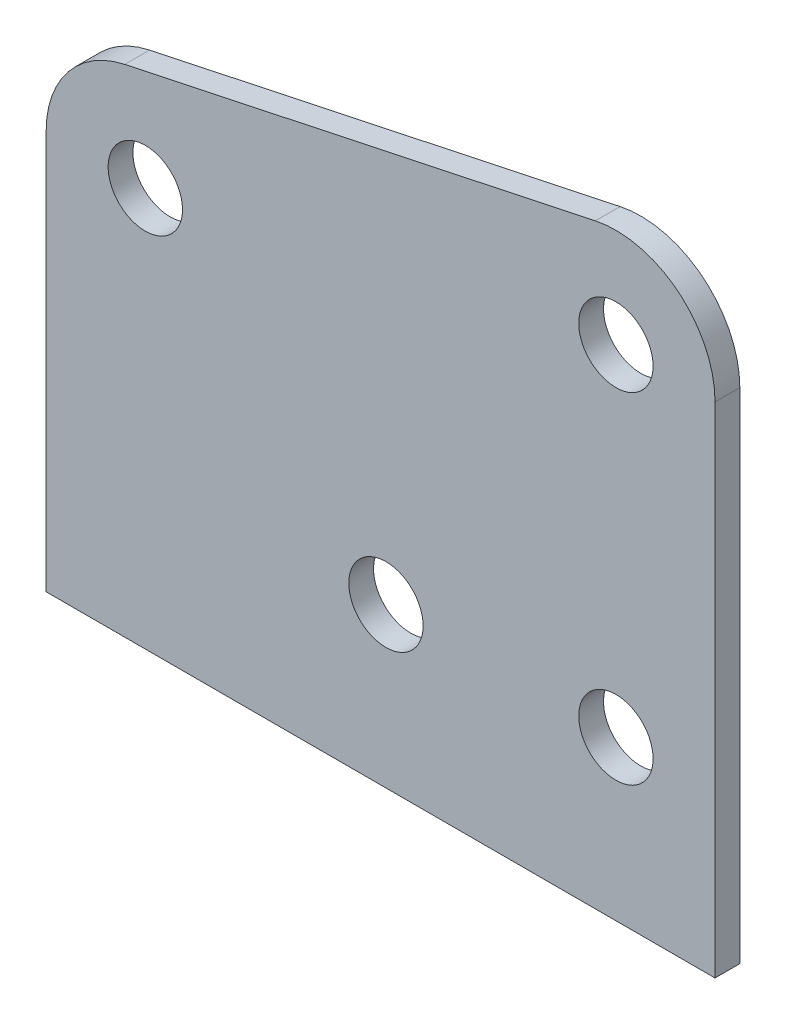
from build123d import *

# Parameters (mm, degrees)
SKETCH1_R           = 4.7625
BOSS_EXTRUDE1_DEPTH = 3.175


with BuildPart() as part:
    # Sketch1 → Boss-Extrude1 (new body)
    with BuildSketch(Plane.XY):
        with BuildLine():
            Line((18.052936785, 76.341523137), (-42.240313215, 63.554909137))
            ThreePointArc((-42.240313215, 63.554909137), (-49.473481519, 59.125864726), (-52.305574358, 51.131216))
            Line((-52.305574358, 51.131216), (-52.305574358, 0))
            Line((-52.305574358, 0), (33.387675642, 0))
            Line((33.387675642, 0), (33.387675642, 63.91783))
            ThreePointArc((33.387675642, 63.91783), (28.682324369, 73.785737161), (18.052936785, 76.341523137))
        make_face()
        with Locations((20.687675642, 20.35683)):
            Circle(SKETCH1_R, mode=Mode.SUBTRACT)
        with Locations((20.687675642, 63.91783)):
            Circle(SKETCH1_R, mode=Mode.SUBTRACT)
        with Locations((-8.776324358, 20.35683)):
            Circle(SKETCH1_R, mode=Mode.SUBTRACT)
        with Locations((-39.605574358, 51.131216)):
            Circle(SKETCH1_R, mode=Mode.SUBTRACT)
    extrude(amount=BOSS_EXTRUDE1_DEPTH)


solid = part.part
